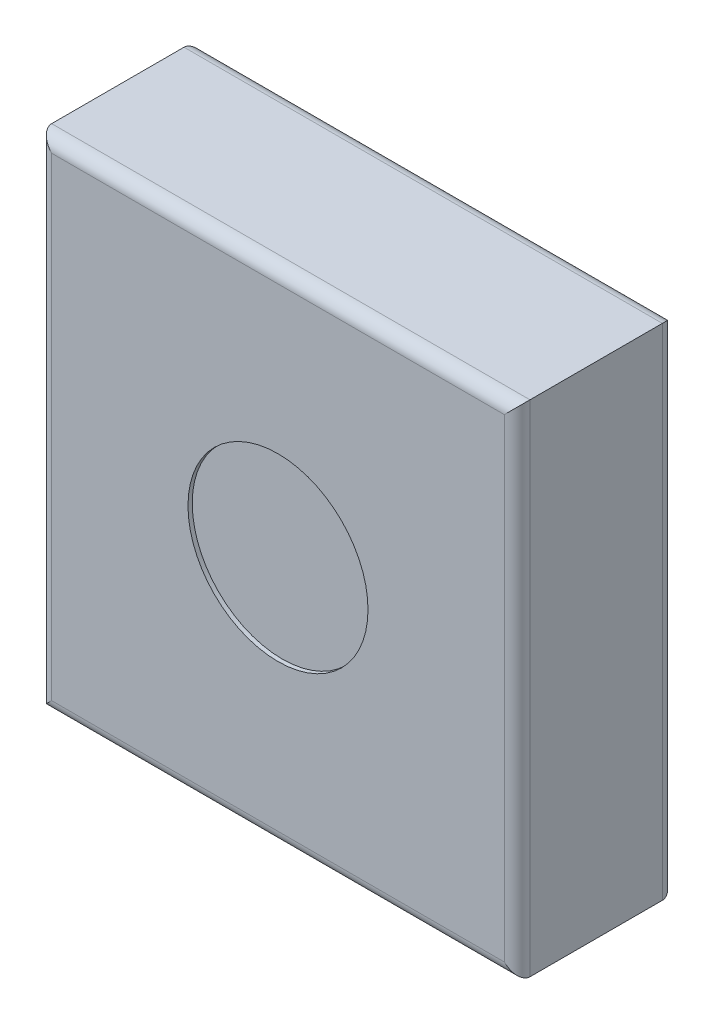
from build123d import *

# Parameters (mm, degrees)
SKETCH_1_W          = 112
SKETCH_1_H          = 117
EXTRUDE_1_DEPTH     = 37
FILLET_1_R          = 3
FILLET_2_R          = 3
SKETCH_2_R          = 21.074583211
CUT_EXTRUDE_1_DEPTH = 1


with BuildPart() as part:
    # 草图1 → 凸台-拉伸1 (new body)
    with BuildSketch(Plane.XY):
        Rectangle(SKETCH_1_W, SKETCH_1_H)
    extrude(amount=EXTRUDE_1_DEPTH)

    # 圆角1
    fillet_1_edges = [part.edges().sort_by_distance(p)[0] for p in [
        (-56, 0, 37),
        (0, -58.5, 37),
        (56, 0, 37),
        (0, 58.5, 37),
    ]]
    fillet(fillet_1_edges, radius=FILLET_1_R)

    # 圆角2
    fillet_2_edges = [part.edges().sort_by_distance(p)[0] for p in [
        (0, -58.5, 0),
        (-56, 0, 0),
        (0, 58.5, 0),
        (56, 0, 0),
    ]]
    fillet(fillet_2_edges, radius=FILLET_2_R)

    # 草图2 → 切除-拉伸1 (cut)
    with BuildSketch(Plane.XY.offset(37)):
        Circle(SKETCH_2_R)
    extrude(amount=-CUT_EXTRUDE_1_DEPTH, mode=Mode.SUBTRACT)


solid = part.part
